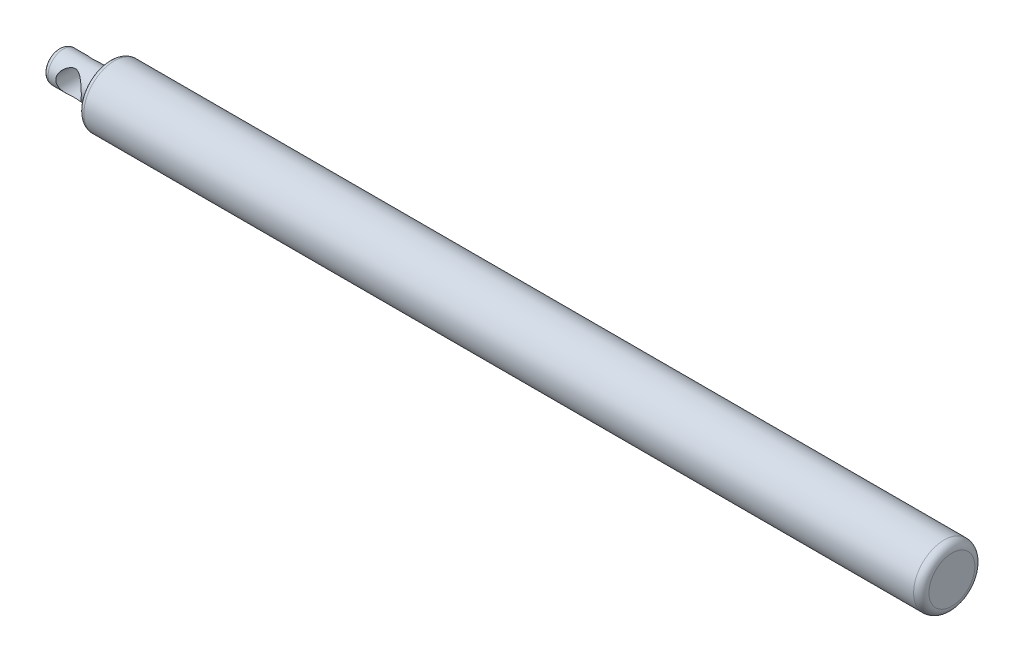
from build123d import *

# Parameters (mm, degrees)
SKETCH2_R               = 2.5
CUT_EXTRUDE1_DEPTH      = 7
CUT_EXTRUDE1_DEPTH_BACK = 7
FILLET2_R               = 1
FILLET3_R               = 1
FILLET4_R               = 1.5


with BuildPart() as part:
    # Sketch1 → Revolve1 (revolve)
    with BuildSketch(Plane.XY):
        Polygon((0, 3), (10, 3), (10, 6), (175, 6), (175, 0), (0, 0), align=None)
    revolve(axis=Axis((0, 0, 0), (1, 0, 0)))

    # Sketch2 → Cut-Extrude1 (cut, two sides)
    with BuildSketch(Plane.XY) as cut_extrude1_sk:
        with Locations((5, 0)):
            Circle(SKETCH2_R)
    extrude(amount=CUT_EXTRUDE1_DEPTH, mode=Mode.SUBTRACT)
    extrude(cut_extrude1_sk.sketch, amount=-CUT_EXTRUDE1_DEPTH_BACK, mode=Mode.SUBTRACT)

    # Fillet2
    fillet2_edges = [part.edges().sort_by_distance(p)[0] for p in [
        (0, -3, 0),
    ]]
    fillet(fillet2_edges, radius=FILLET2_R)

    # Fillet3
    fillet3_edges = [part.edges().sort_by_distance(p)[0] for p in [
        (10, -6, 0),
        (10, -3, 0),
    ]]
    fillet(fillet3_edges, radius=FILLET3_R)

    # Fillet4
    fillet4_edges = [part.edges().sort_by_distance(p)[0] for p in [
        (175, -6, 0),
    ]]
    fillet(fillet4_edges, radius=FILLET4_R)


solid = part.part
